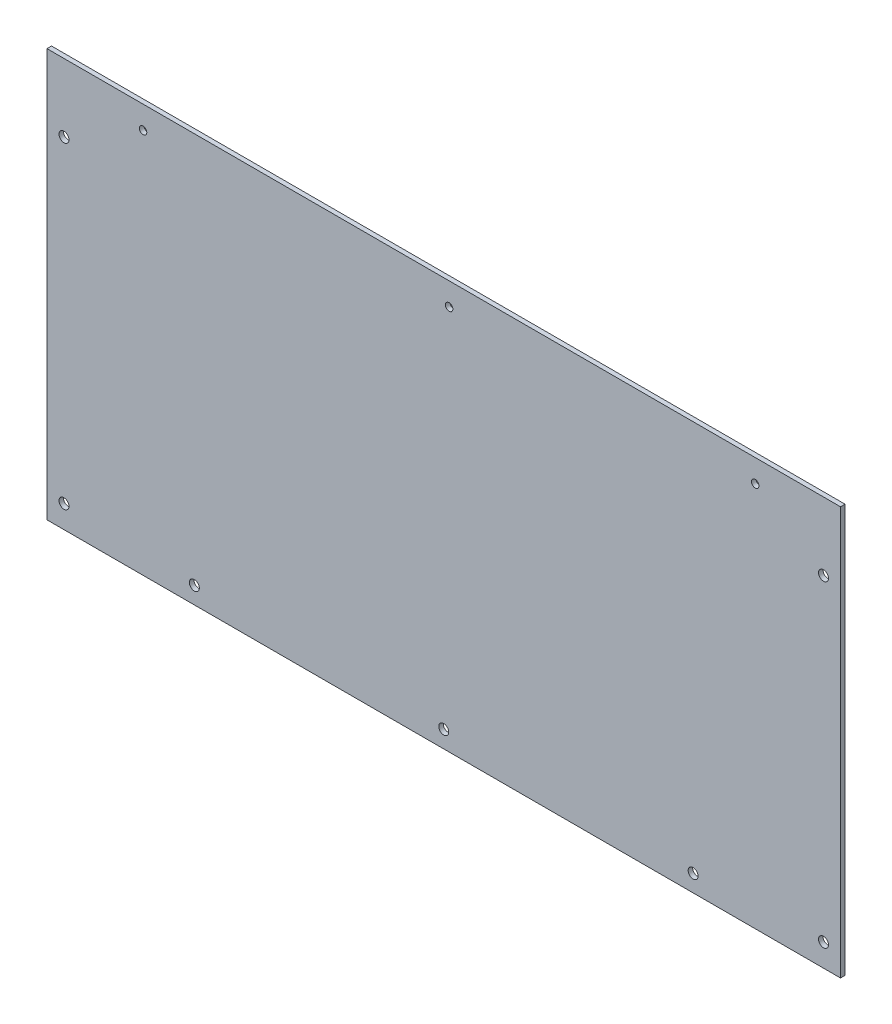
from build123d import *

# Parameters (mm, degrees)
SKETCH_1_W          = 350
SKETCH_1_H          = 180
EXTRUDE_1_DEPTH     = 2
CUT_EXTRUDE_1_DEPTH = 2
SKETCH_3_R          = 2.2
CUT_EXTRUDE_2_DEPTH = 160
SKETCH_4_R          = 2.2
CUT_EXTRUDE_3_DEPTH = 160
SKETCH_5_R          = 1
CUT_EXTRUDE_4_DEPTH = 10
M4X0_7_1_D          = 3.3


with BuildPart() as part:
    # ｽｹｯﾁ1 → ﾎﾞｽ - 押し出し1 (new body)
    with BuildSketch(Plane.XY):
        Rectangle(SKETCH_1_W, SKETCH_1_H)
    extrude(amount=EXTRUDE_1_DEPTH)

    # ｽｹｯﾁ2 → ｶｯﾄ - 押し出し1 (cut)
    with BuildSketch(Plane.XY.offset(2)):
        with BuildLine():
            ThreePointArc((-131.62, 80), (-131.912893219, 80.707106781), (-132.62, 81))
            Line((-132.62, 81), (-132.62, 80))
            Line((-132.62, 80), (-133.62, 80))
            ThreePointArc((-133.62, 80), (-132.62, 79), (-131.62, 80))
        make_face()
        with BuildLine():
            Line((-132.62, 80), (-132.62, 81))
            ThreePointArc((-132.62, 81), (-133.327106781, 80.707106781), (-133.62, 80))
            Line((-133.62, 80), (-132.62, 80))
        make_face()
        with BuildLine():
            ThreePointArc((138.38, 80), (138.087106781, 80.707106781), (137.38, 81))
            Line((137.38, 81), (137.38, 80))
            Line((137.38, 80), (138.38, 80))
        make_face()
        with BuildLine():
            Line((137.38, 80), (137.38, 81))
            ThreePointArc((137.38, 81), (136.672893219, 79.292893219), (138.38, 80))
            Line((138.38, 80), (137.38, 80))
        make_face()
    extrude(amount=-CUT_EXTRUDE_1_DEPTH, mode=Mode.SUBTRACT)

    # ｽｹｯﾁ3 → ｶｯﾄ - 押し出し2 (cut)
    with BuildSketch(Plane.XY.offset(2)):
        with Locations((-167.5, 60)):
            Circle(SKETCH_3_R)
        with Locations((-167.5, -80)):
            Circle(SKETCH_3_R)
        with Locations((167.5, 60)):
            Circle(SKETCH_3_R)
        with Locations((167.5, -80)):
            Circle(SKETCH_3_R)
    extrude(amount=-CUT_EXTRUDE_2_DEPTH, mode=Mode.SUBTRACT)

    # ｽｹｯﾁ4 → ｶｯﾄ - 押し出し3 (cut)
    with BuildSketch(Plane.XY.offset(2)):
        with Locations((-110, -82.5)):
            Circle(SKETCH_4_R)
        with Locations((0, -82.5)):
            Circle(SKETCH_4_R)
        with Locations((110, -82.5)):
            Circle(SKETCH_4_R)
    extrude(amount=-CUT_EXTRUDE_3_DEPTH, mode=Mode.SUBTRACT)

    # ｽｹｯﾁ5 → ｶｯﾄ - 押し出し4 (cut)
    with BuildSketch(Plane.XY.offset(2)):
        with Locations((2.38, 80)):
            Circle(SKETCH_5_R)
    extrude(amount=-CUT_EXTRUDE_4_DEPTH, mode=Mode.SUBTRACT)

    # M4x0.7 ねじ穴1 (through all)
    with Locations(Plane(origin=(-132.62, 80, 2), x_dir=(1, 0, 0), z_dir=(0, 0, 1))):
        with Locations((0, 0), (135, 0), (270, 0)):
            Hole(M4X0_7_1_D / 2)


solid = part.part
